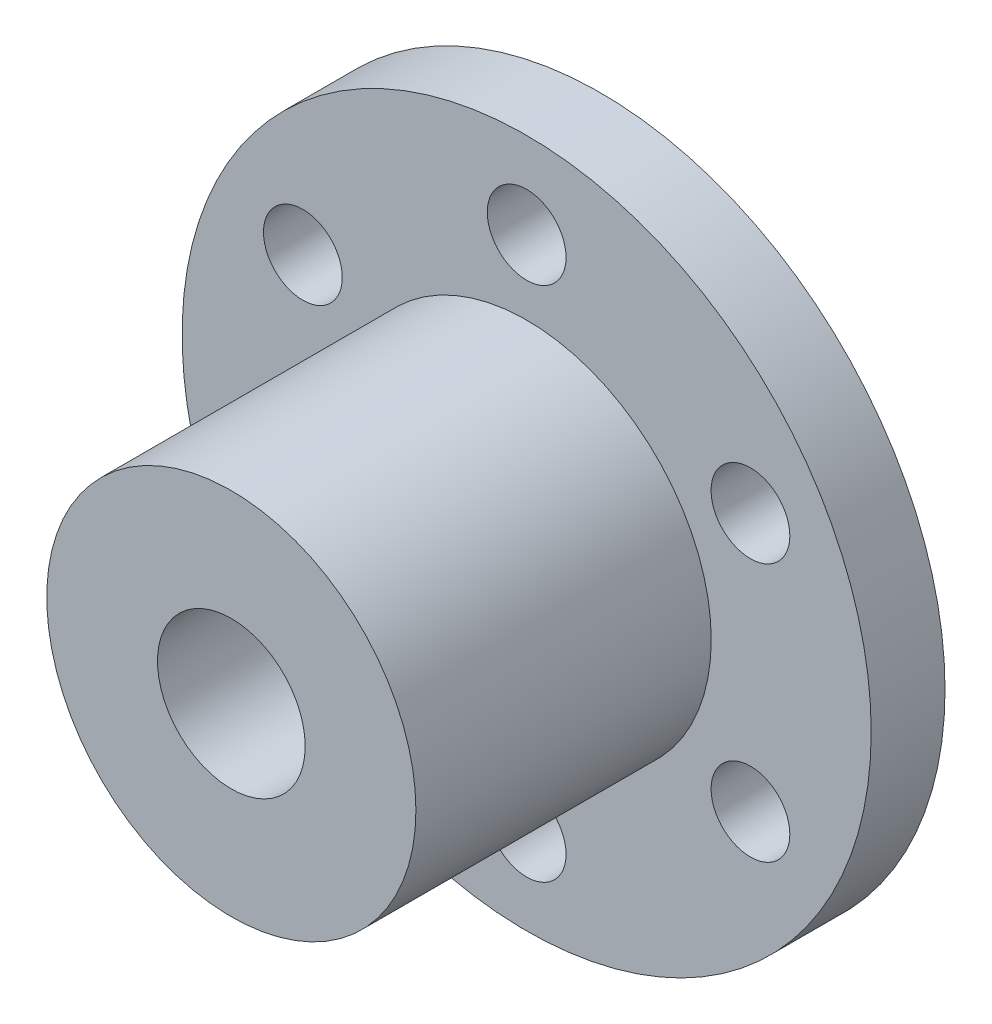
from build123d import *

# Parameters (mm, degrees)
SKETCH_1_R          = 14
EXTRUDE_1_DEPTH     = 3
SKETCH_2_R          = 7.5
SKETCH_2_R_2        = 3
EXTRUDE_2_DEPTH     = 12
SKETCH_3_R          = 3
CUT_EXTRUDE_1_DEPTH = 4
SKETCH_4_R          = 1.6
CUT_EXTRUDE_2_DEPTH = 16


with BuildPart() as part:
    # 草图1 → 凸台-拉伸1 (new body)
    with BuildSketch(Plane.XY):
        Circle(SKETCH_1_R)
    extrude(amount=EXTRUDE_1_DEPTH)

    # 草图2 → 凸台-拉伸2 (add)
    with BuildSketch(Plane.XY.offset(3)):
        Circle(SKETCH_2_R)
        Circle(SKETCH_2_R_2, mode=Mode.SUBTRACT)
    extrude(amount=EXTRUDE_2_DEPTH)

    # 草图3 → 切除-拉伸1 (cut, through all)
    with BuildSketch(Plane.XY.offset(3)):
        Circle(SKETCH_3_R)
    extrude(amount=-CUT_EXTRUDE_1_DEPTH, mode=Mode.SUBTRACT)

    # 草图4 → 切除-拉伸2 (cut, through all)
    with BuildSketch(Plane(origin=(0, 0, 0), x_dir=(-1, 0, 0), z_dir=(0, 0, -1))):
        with Locations((-9.09326674, -5.25)):
            Circle(SKETCH_4_R)
        with Locations((9.09326674, 5.25)):
            Circle(SKETCH_4_R)
        with Locations((0, -10.5)):
            Circle(SKETCH_4_R)
        with Locations((9.09326674, -5.25)):
            Circle(SKETCH_4_R)
        with Locations((0, 10.5)):
            Circle(SKETCH_4_R)
        with Locations((-9.09326674, 5.25)):
            Circle(SKETCH_4_R)
    extrude(amount=-CUT_EXTRUDE_2_DEPTH, mode=Mode.SUBTRACT)


solid = part.part
